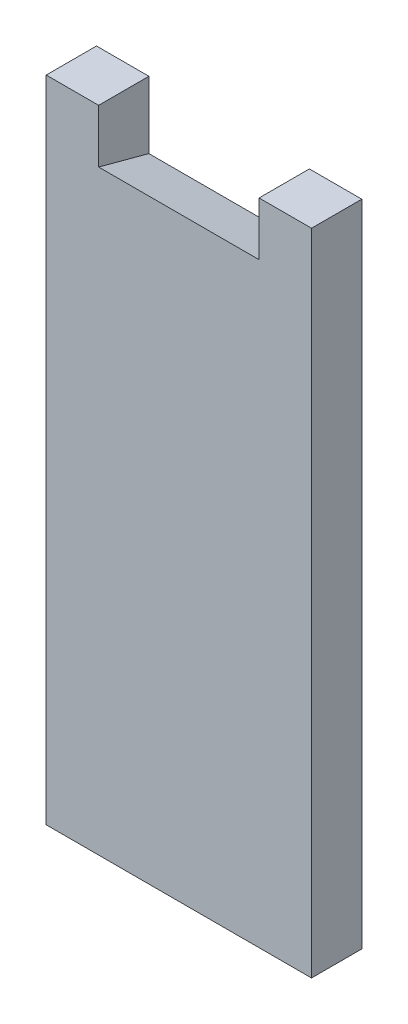
from build123d import *

# Parameters (mm, degrees)
EXTRUDE_1_DEPTH = 9.4
DRAFT_5_ANGLE   = -15


with BuildPart() as part:
    # 草图1 → 凸台-拉伸1 (new body)
    with BuildSketch(Plane.XY):
        Polygon((9.8, 0), (0, 0), (0, -121.4), (49.6, -121.4), (49.6, 0), (39.8, 0), (39.8, -10), (9.8, -10), align=None)
    extrude(amount=EXTRUDE_1_DEPTH)

    # 拔模5
    draft_5_faces = [part.faces().sort_by_distance(p)[0] for p in [
        (24.8, -10, 4.7),
    ]]
    draft(draft_5_faces, Plane.XY.offset(9.4), DRAFT_5_ANGLE)


solid = part.part
